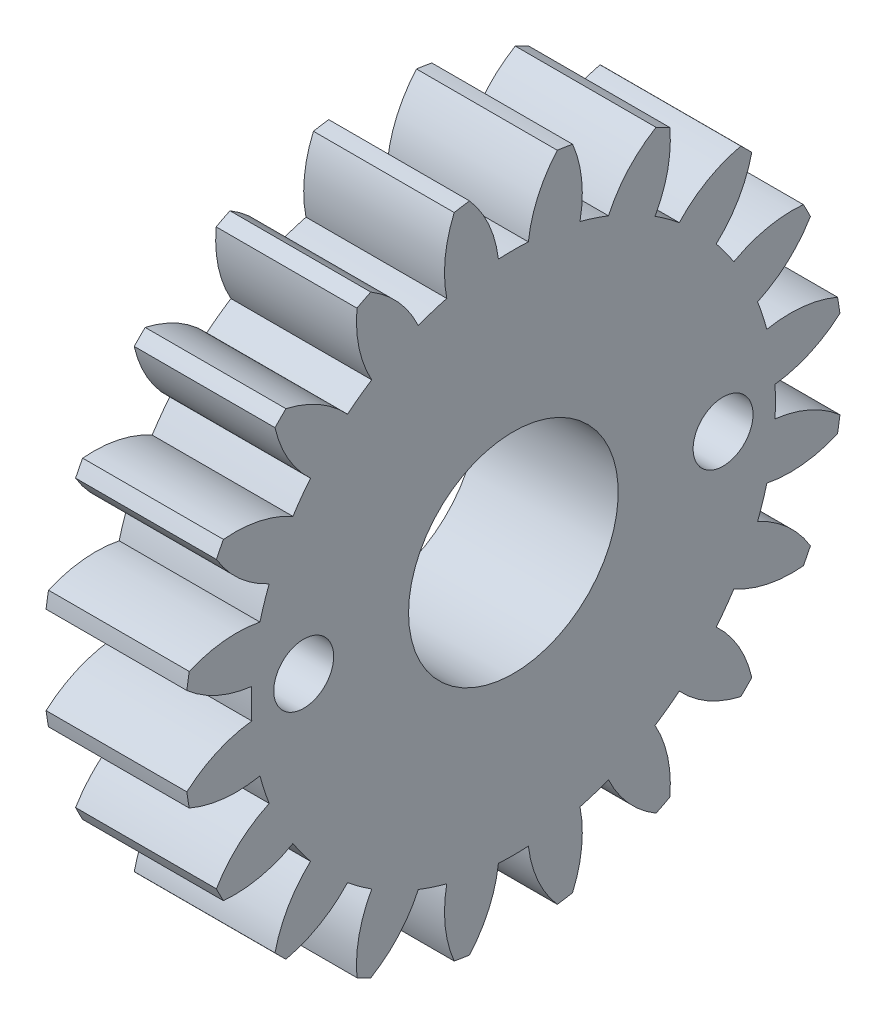
from build123d import *

# Parameters (mm, degrees)
BASPROSKE_W        = 4.7
BASPROSKE_H        = 11
TOOTHCUT_DEPTH     = 17.250846132
TEETHCUTS_COUNT    = 20
TEETHCUTS_ANGLE    = 342
BORSKE_R           = 3.5
BORE_DEPTH         = 50.0000508
SKETCH1_R          = 1
CUT_EXTRUDE1_DEPTH = 17.118244485


with BuildPart() as part:
    # BasProSke → Base-Revolve (revolve)
    with BuildSketch(Plane(origin=(0, 0, 0), x_dir=(1, 0, 0), z_dir=(0, 1, 0)), mode=Mode.PRIVATE) as base_revolve_sk:
        with Locations((2.35, 5.5)):
            Rectangle(BASPROSKE_W, BASPROSKE_H)
    revolve(base_revolve_sk.sketch.rotate(Axis((-10, 0, 0), (1, 0, 0)), 180), axis=Axis((-10, 0, 0), (1, 0, 0)))

    # TooCutSke → ToothCut (cut, through all)
    with BuildSketch(Plane(origin=(0, 0, 0), x_dir=(0, 0, -1), z_dir=(1, 0, 0))):
        with BuildLine():
            ThreePointArc((0.499924007, 8.734705318), (0, 8.749), (-0.499924007, 8.734705318))
            ThreePointArc((-0.499924007, 8.734705318), (-0.824302243, 9.905497836), (-1.485192705, 10.924909509))
            ThreePointArc((-1.485192705, 10.924909509), (0, 11.0254), (1.485192705, 10.924909509))
            ThreePointArc((1.485192705, 10.924909509), (0.824302243, 9.905497836), (0.499924007, 8.734705318))
        make_face()
    toothcut = extrude(amount=TOOTHCUT_DEPTH, mode=Mode.SUBTRACT)

    # TeethCuts: ToothCut ×20 about axis
    teethcuts_axis = Axis((-10, 0, 0), (1, 0, 0))
    for i in range(1, TEETHCUTS_COUNT):
        add(toothcut.rotate(teethcuts_axis, i * TEETHCUTS_ANGLE / (TEETHCUTS_COUNT - 1)), mode=Mode.SUBTRACT)

    # BorSke → Bore (cut, symmetric)
    with BuildSketch(Plane(origin=(0, 0, 0), x_dir=(0, 0, -1), z_dir=(1, 0, 0))):
        with Locations(Location((0, 0, 0), (0, 0, 180))):
            Circle(BORSKE_R)
    extrude(amount=BORE_DEPTH, both=True, mode=Mode.SUBTRACT)

    # Sketch1 → Cut-Extrude1 (cut, through all)
    with BuildSketch(Plane(origin=(4.7, 0, 0), x_dir=(0, 0, -1), z_dir=(1, 0, 0))):
        with Locations((-7, 0)):
            Circle(SKETCH1_R)
        with Locations((7, 0)):
            Circle(SKETCH1_R)
    extrude(amount=-CUT_EXTRUDE1_DEPTH, mode=Mode.SUBTRACT)


solid = part.part
